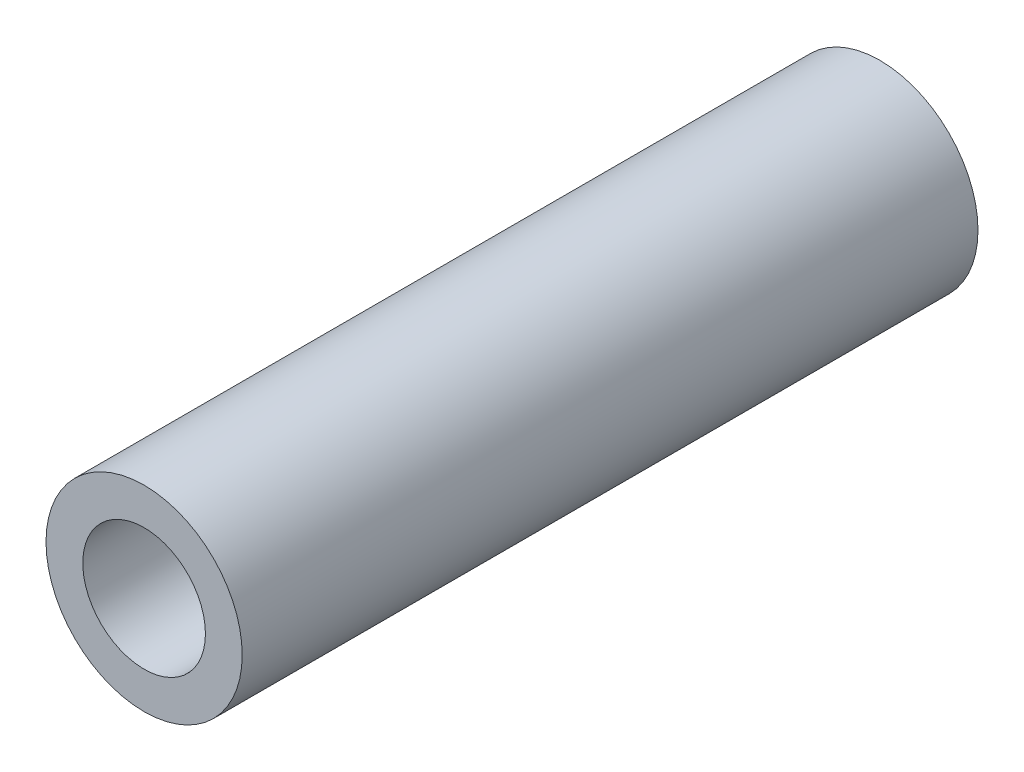
from build123d import *

# Parameters (mm, degrees)
SKETCH1_R           = 1.6
SKETCH1_R_2         = 1
BOSS_EXTRUDE1_DEPTH = 12


with BuildPart() as part:
    # Sketch1 → Boss-Extrude1 (new body)
    with BuildSketch(Plane.XY):
        Circle(SKETCH1_R)
        Circle(SKETCH1_R_2, mode=Mode.SUBTRACT)
    extrude(amount=BOSS_EXTRUDE1_DEPTH)


solid = part.part
